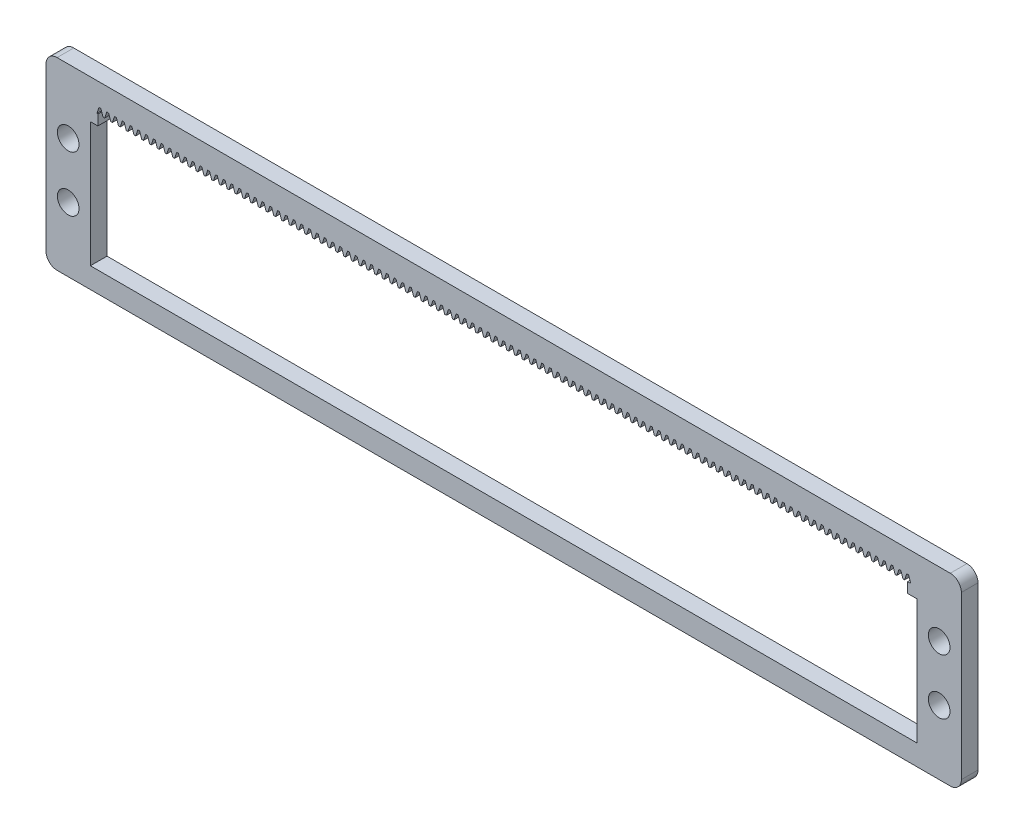
from build123d import *

# Parameters (mm, degrees)
BOSS_EXTRUDE1_DEPTH = 3
SKETCH2_W           = 149
SKETCH2_H           = 22.5
CUT_EXTRUDE1_DEPTH  = 4
SKETCH3_W           = 145.97
SKETCH3_H           = 1.85
CUT_EXTRUDE2_DEPTH  = 4
CUT_EXTRUDE4_DEPTH  = 4
LPATTERN1_COUNT     = 105
LPATTERN1_PITCH     = 1.4
SKETCH5_R           = 1.95
CUT_EXTRUDE5_DEPTH  = 10


with BuildPart() as part:
    # Sketch1 → Boss-Extrude1 (new body)
    with BuildSketch(Plane.XY):
        with BuildLine():
            Line((2, 0), (163, 0))
            ThreePointArc((163, 0), (164.414213562, -0.585786438), (165, -2))
            Line((165, -2), (165, -31.22))
            ThreePointArc((165, -31.22), (164.414213562, -32.634213562), (163, -33.22))
            Line((163, -33.22), (2, -33.22))
            ThreePointArc((2, -33.22), (0.585786438, -32.634213562), (0, -31.22))
            Line((0, -31.22), (0, -2))
            ThreePointArc((0, -2), (0.585786438, -0.585786438), (2, 0))
        make_face()
    extrude(amount=BOSS_EXTRUDE1_DEPTH)

    # Sketch2 → Cut-Extrude1 (cut, through all)
    with BuildSketch(Plane.XY.offset(3)):
        with Locations((82.5, -18.25)):
            Rectangle(SKETCH2_W, SKETCH2_H)
    extrude(amount=-CUT_EXTRUDE1_DEPTH, mode=Mode.SUBTRACT)

    # Sketch3 → Cut-Extrude2 (cut, through all)
    with BuildSketch(Plane.XY.offset(3)):
        with Locations((82.335, -6.075)):
            Rectangle(SKETCH3_W, SKETCH3_H)
    extrude(amount=-CUT_EXTRUDE2_DEPTH, mode=Mode.SUBTRACT)

    # Sketch4 → Cut-Extrude4 (cut, through all)
    with BuildSketch(Plane.XY.offset(3)):
        Polygon((155.485, -4.011755738), (155.865, -5.15), (154.775, -5.15), (155.155, -4.011755738), align=None)
    cut_extrude4 = extrude(amount=-CUT_EXTRUDE4_DEPTH, mode=Mode.SUBTRACT)

    # LPattern1: Cut-Extrude4 ×105
    with Locations(*[(-i * LPATTERN1_PITCH, 0, 0) for i in range(1, LPATTERN1_COUNT)]):
        add(cut_extrude4, mode=Mode.SUBTRACT)

    # Sketch5 → Cut-Extrude5 (cut)
    with BuildSketch(Plane.XY.offset(3)):
        with Locations((4, -11.61)):
            Circle(SKETCH5_R)
        with Locations((4, -21.61)):
            Circle(SKETCH5_R)
        with Locations((161, -11.61)):
            Circle(SKETCH5_R)
        with Locations((161, -21.61)):
            Circle(SKETCH5_R)
    extrude(amount=-CUT_EXTRUDE5_DEPTH, mode=Mode.SUBTRACT)


solid = part.part
